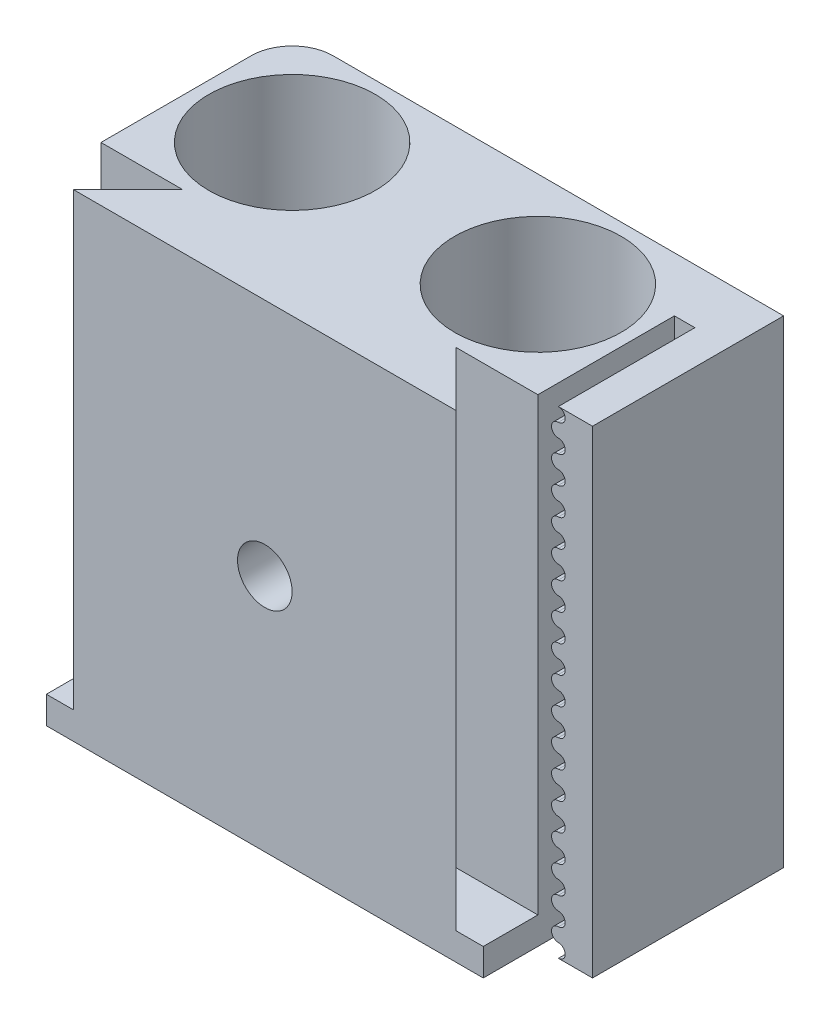
from build123d import *

# Parameters (mm, degrees)
SKETCH_1_W          = 32
SKETCH_1_H          = 35
EXTRUDE_1_DEPTH     = 14
CUT_EXTRUDE_1_REACH = 37
SKETCH_2_R          = 6.1
EXTRUDE_2_DEPTH     = 33
SKETCH_5_W          = 32
SKETCH_5_H          = 4
EXTRUDE_3_DEPTH     = 2
FILLET_1_R          = 3
SKETCH_6_W          = 14
SKETCH_6_H          = 35
EXTRUDE_4_DEPTH     = 4
CUT_EXTRUDE_2_DEPTH = 10
CUT_EXTRUDE_3_REACH = 20
SKETCH_9_R          = 2
CUT_EXTRUDE_4_DEPTH = 3.5


with BuildPart() as part:
    # Эскиз1 → Бобышка-Вытянуть1 (new body)
    with BuildSketch(Plane.XY):
        Rectangle(SKETCH_1_W, SKETCH_1_H)
    extrude(amount=EXTRUDE_1_DEPTH)

    # Эскиз2 → Вырез-Вытянуть1 (cut, up to next)
    with BuildSketch(Plane(origin=(0, 17.5, 0), x_dir=(1, 0, 0), z_dir=(0, 1, 0)), mode=Mode.PRIVATE) as cut_extrude_1_sk1:
        with Locations((-9, -7)):
            Circle(SKETCH_2_R)
    cut_extrude_1_tool1 = extrude(cut_extrude_1_sk1.sketch, amount=-CUT_EXTRUDE_1_REACH, mode=Mode.PRIVATE) & part.part
    add(cut_extrude_1_tool1.solids().sort_by_distance((-9, 17.5, 7))[0], mode=Mode.SUBTRACT)
    # Эскиз2 → Вырез-Вытянуть1 (cut, up to next)
    with BuildSketch(Plane(origin=(0, 17.5, 0), x_dir=(1, 0, 0), z_dir=(0, 1, 0)), mode=Mode.PRIVATE) as cut_extrude_1_sk2:
        with Locations((9, -7)):
            Circle(SKETCH_2_R)
    cut_extrude_1_tool2 = extrude(cut_extrude_1_sk2.sketch, amount=-CUT_EXTRUDE_1_REACH, mode=Mode.PRIVATE) & part.part
    add(cut_extrude_1_tool2.solids().sort_by_distance((9, 17.5, 7))[0], mode=Mode.SUBTRACT)

    # Эскиз3 → Бобышка-Вытянуть2 (add)
    with BuildSketch(Plane(origin=(0, 17.5, 0), x_dir=(1, 0, 0), z_dir=(0, 1, 0))):
        Polygon((-14, -18), (-10, -14), (10, -14), (14, -18), align=None)
    extrude(amount=-EXTRUDE_2_DEPTH)

    # Эскиз5 → Бобышка-Вытянуть3 (add)
    with BuildSketch(Plane.XZ.offset(15.5)):
        with Locations((0, 16)):
            Rectangle(SKETCH_5_W, SKETCH_5_H)
    extrude(amount=EXTRUDE_3_DEPTH)

    # Скругление1
    fillet_1_edges = [part.edges().sort_by_distance(p)[0] for p in [
        (-16, 0, 0),
    ]]
    fillet(fillet_1_edges, radius=FILLET_1_R)

    # Эскиз6 → Бобышка-Вытянуть4 (add)
    with BuildSketch(Plane(origin=(16, 0, 0), x_dir=(0, 0, -1), z_dir=(1, 0, 0))):
        with Locations((-7, 0)):
            Rectangle(SKETCH_6_W, SKETCH_6_H)
    extrude(amount=EXTRUDE_4_DEPTH)

    # Эскиз7 → Вырез-Вытянуть2 (cut)
    with BuildSketch(Plane.XY.offset(14)):
        with BuildLine():
            Line((16, -17.5), (17.5, -17.5))
            ThreePointArc((17.5, -17.5), (18, -17), (17.5, -16.5))
            ThreePointArc((17.5, -16.5), (17, -16), (17.5, -15.5))
            ThreePointArc((17.5, -15.5), (18, -15), (17.5, -14.5))
            ThreePointArc((17.5, -14.5), (17, -14), (17.5, -13.5))
            ThreePointArc((17.5, -13.5), (18, -13), (17.5, -12.5))
            ThreePointArc((17.5, -12.5), (17, -12), (17.5, -11.5))
            ThreePointArc((17.5, -11.5), (18, -11), (17.5, -10.5))
            ThreePointArc((17.5, -10.5), (17, -10), (17.5, -9.5))
            ThreePointArc((17.5, -9.5), (18, -9), (17.5, -8.5))
            ThreePointArc((17.5, -8.5), (17, -8), (17.5, -7.5))
            ThreePointArc((17.5, -7.5), (18, -7), (17.5, -6.5))
            ThreePointArc((17.5, -6.5), (17, -6), (17.5, -5.5))
            ThreePointArc((17.5, -5.5), (18, -5), (17.5, -4.5))
            ThreePointArc((17.5, -4.5), (17, -4), (17.5, -3.5))
            ThreePointArc((17.5, -3.5), (18, -3), (17.5, -2.5))
            ThreePointArc((17.5, -2.5), (17, -2), (17.5, -1.5))
            ThreePointArc((17.5, -1.5), (18, -1), (17.5, -0.5))
            ThreePointArc((17.5, -0.5), (17, 0), (17.5, 0.5))
            ThreePointArc((17.5, 0.5), (18, 1), (17.5, 1.5))
            ThreePointArc((17.5, 1.5), (17, 2), (17.5, 2.5))
            ThreePointArc((17.5, 2.5), (18, 3), (17.5, 3.5))
            ThreePointArc((17.5, 3.5), (17, 4), (17.5, 4.5))
            ThreePointArc((17.5, 4.5), (18, 5), (17.5, 5.5))
            ThreePointArc((17.5, 5.5), (17, 6), (17.5, 6.5))
            ThreePointArc((17.5, 6.5), (18, 7), (17.5, 7.5))
            ThreePointArc((17.5, 7.5), (17, 8), (17.5, 8.5))
            ThreePointArc((17.5, 8.5), (18, 9), (17.5, 9.5))
            ThreePointArc((17.5, 9.5), (17, 10), (17.5, 10.5))
            ThreePointArc((17.5, 10.5), (18, 11), (17.5, 11.5))
            ThreePointArc((17.5, 11.5), (17, 12), (17.5, 12.5))
            ThreePointArc((17.5, 12.5), (18, 13), (17.5, 13.5))
            ThreePointArc((17.5, 13.5), (17, 14), (17.5, 14.5))
            ThreePointArc((17.5, 14.5), (18, 15), (17.5, 15.5))
            ThreePointArc((17.5, 15.5), (17, 16), (17.5, 16.5))
            ThreePointArc((17.5, 16.5), (18, 17), (17.5, 17.5))
            Line((17.5, 17.5), (16, 17.5))
            Line((16, 17.5), (16, -17.5))
        make_face()
    extrude(amount=-CUT_EXTRUDE_2_DEPTH, mode=Mode.SUBTRACT)

    # Эскиз9 → Вырез-Вытянуть3 (cut, up to next)
    with BuildSketch(Plane.XY.offset(18), mode=Mode.PRIVATE) as cut_extrude_3_sk1:
        Circle(SKETCH_9_R)
    cut_extrude_3_tool1 = extrude(cut_extrude_3_sk1.sketch, amount=-CUT_EXTRUDE_3_REACH, mode=Mode.PRIVATE) & part.part
    add(cut_extrude_3_tool1.solids().sort_by_distance((0, 0, 18))[0], mode=Mode.SUBTRACT)

    # Эскиз10 → Вырез-Вытянуть4 (cut)
    with BuildSketch(Plane(origin=(0, 0, 0), x_dir=(-1, 0, 0), z_dir=(0, 0, -1))):
        Polygon((0, -4.041451884), (3.5, -2.020725942), (3.5, 2.020725942), (0, 4.041451884), (-3.5, 2.020725942), (-3.5, -2.020725942), align=None)
    extrude(amount=-CUT_EXTRUDE_4_DEPTH, mode=Mode.SUBTRACT)


solid = part.part
